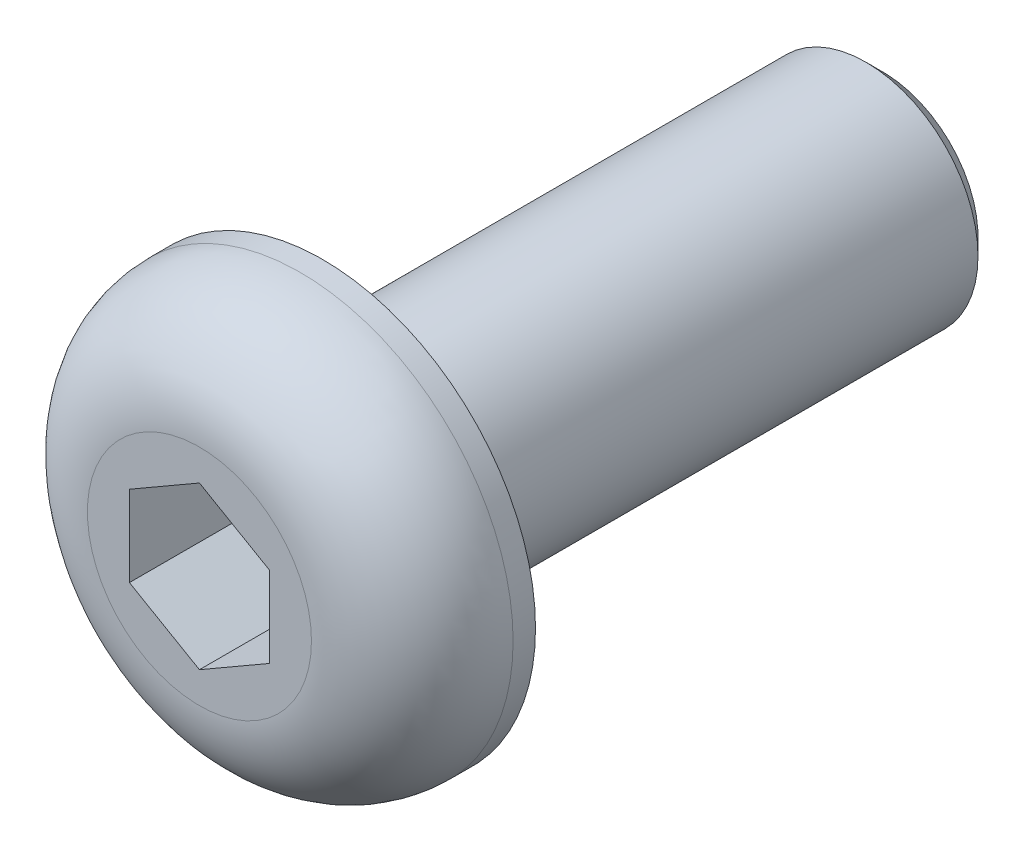
from build123d import *

# Parameters (mm, degrees)
SKETCH1_R           = 3.8
BOSS_EXTRUDE1_DEPTH = 2.2
SKETCH2_R           = 2
BOSS_EXTRUDE2_DEPTH = 10
CHAMFER1_SIZE       = 0.3
CUT_EXTRUDE1_DEPTH  = 2
FILLET1_R           = 1.8


with BuildPart() as part:
    # Sketch1 → Boss-Extrude1 (new body)
    with BuildSketch(Plane.XY):
        Circle(SKETCH1_R)
    extrude(amount=BOSS_EXTRUDE1_DEPTH)

    # Sketch2 → Boss-Extrude2 (add)
    with BuildSketch(Plane(origin=(0, 0, 0), x_dir=(-1, 0, 0), z_dir=(0, 0, -1))):
        Circle(SKETCH2_R)
    extrude(amount=BOSS_EXTRUDE2_DEPTH)

    # Chamfer1
    chamfer1_edges = [part.edges().sort_by_distance(p)[0] for p in [
        (2, 0, -10),
    ]]
    chamfer(chamfer1_edges, length=CHAMFER1_SIZE)

    # Sketch3 → Cut-Extrude1 (cut)
    with BuildSketch(Plane.XY.offset(2.2)):
        Polygon((0, 1.443375673), (-1.25, 0.721687836), (-1.25, -0.721687836), (0, -1.443375673), (1.25, -0.721687836), (1.25, 0.721687836), align=None)
    extrude(amount=-CUT_EXTRUDE1_DEPTH, mode=Mode.SUBTRACT)

    # Fillet1
    fillet1_edges = [part.edges().sort_by_distance(p)[0] for p in [
        (-3.8, 0, 2.2),
    ]]
    fillet(fillet1_edges, radius=FILLET1_R)


solid = part.part
